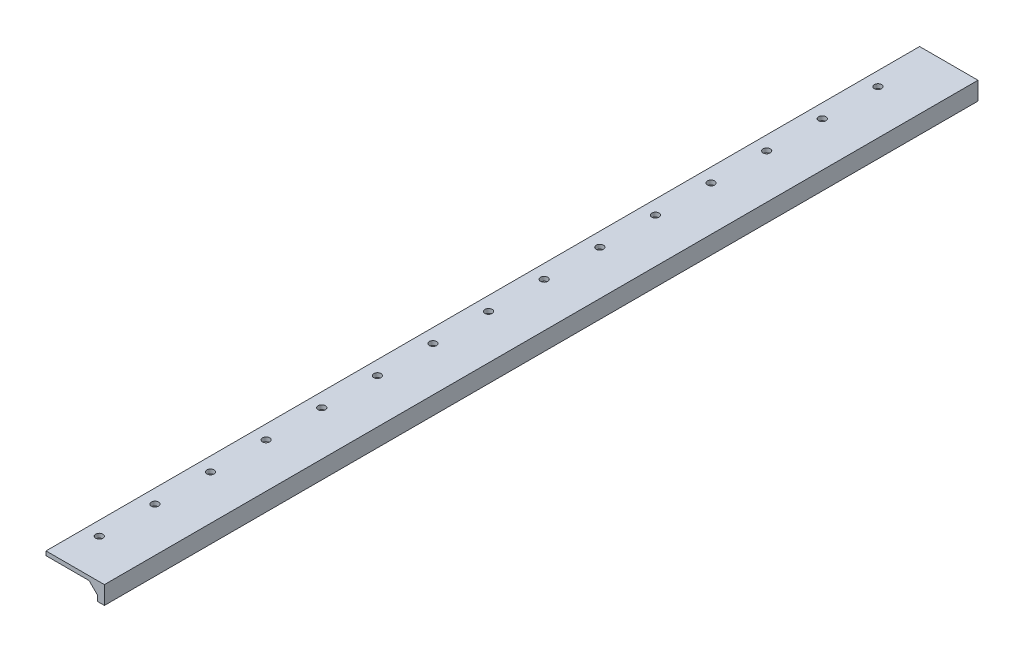
from build123d import *

# Parameters (mm, degrees)
SKETCH_1_W           = 37
SKETCH_1_H           = 628.32
EXTRUDE_1_DEPTH      = 3
SKETCH_2_W           = 5
SKETCH_2_H           = 628.32
EXTRUDE_2_DEPTH      = 10
EXTRUDE_2_DEPTH_BACK = 3
SKETCH_3_R           = 2.6
CUT_EXTRUDE_1_DEPTH  = 10
EXTRUDE_3_DEPTH      = 628.32


with BuildPart() as part:
    # 스케치1 → 보스-돌출1 (new body)
    with BuildSketch(Plane(origin=(0, 0, 0), x_dir=(1, 0, 0), z_dir=(0, 1, 0))):
        with Locations((-18.5, -314.16)):
            Rectangle(SKETCH_1_W, SKETCH_1_H)
    extrude(amount=EXTRUDE_1_DEPTH)

    # 스케치2 → 보스-돌출2 (add, two sides)
    with BuildSketch(Plane.XZ) as extrude_2_sk:
        with Locations((2.5, 314.16)):
            Rectangle(SKETCH_2_W, SKETCH_2_H)
    extrude(amount=EXTRUDE_2_DEPTH)
    extrude(extrude_2_sk.sketch, amount=-EXTRUDE_2_DEPTH_BACK)

    # 스케치3 → 컷-돌출1 (cut)
    with BuildSketch(Plane.XZ):
        with Locations((-27, 40)):
            Circle(SKETCH_3_R)
        with Locations((-27, 80)):
            Circle(SKETCH_3_R)
        with Locations((-27, 120)):
            Circle(SKETCH_3_R)
        with Locations((-27, 160)):
            Circle(SKETCH_3_R)
        with Locations((-27, 200)):
            Circle(SKETCH_3_R)
        with Locations((-27, 240)):
            Circle(SKETCH_3_R)
        with Locations((-27, 280)):
            Circle(SKETCH_3_R)
        with Locations((-27, 320)):
            Circle(SKETCH_3_R)
        with Locations((-27, 360)):
            Circle(SKETCH_3_R)
        with Locations((-27, 400)):
            Circle(SKETCH_3_R)
        with Locations((-27, 440)):
            Circle(SKETCH_3_R)
        with Locations((-27, 480)):
            Circle(SKETCH_3_R)
        with Locations((-27, 520)):
            Circle(SKETCH_3_R)
        with Locations((-27, 560)):
            Circle(SKETCH_3_R)
        with Locations((-27, 600)):
            Circle(SKETCH_3_R)
        with Locations((-27, 640)):
            Circle(SKETCH_3_R)
    extrude(amount=-CUT_EXTRUDE_1_DEPTH, mode=Mode.SUBTRACT)

    # 스케치4 → 보스-돌출3 (add)
    with BuildSketch(Plane.XY.offset(628.32)):
        Polygon((0, 0), (0, -6), (-6, 0), align=None)
    extrude(amount=-EXTRUDE_3_DEPTH)


solid = part.part
